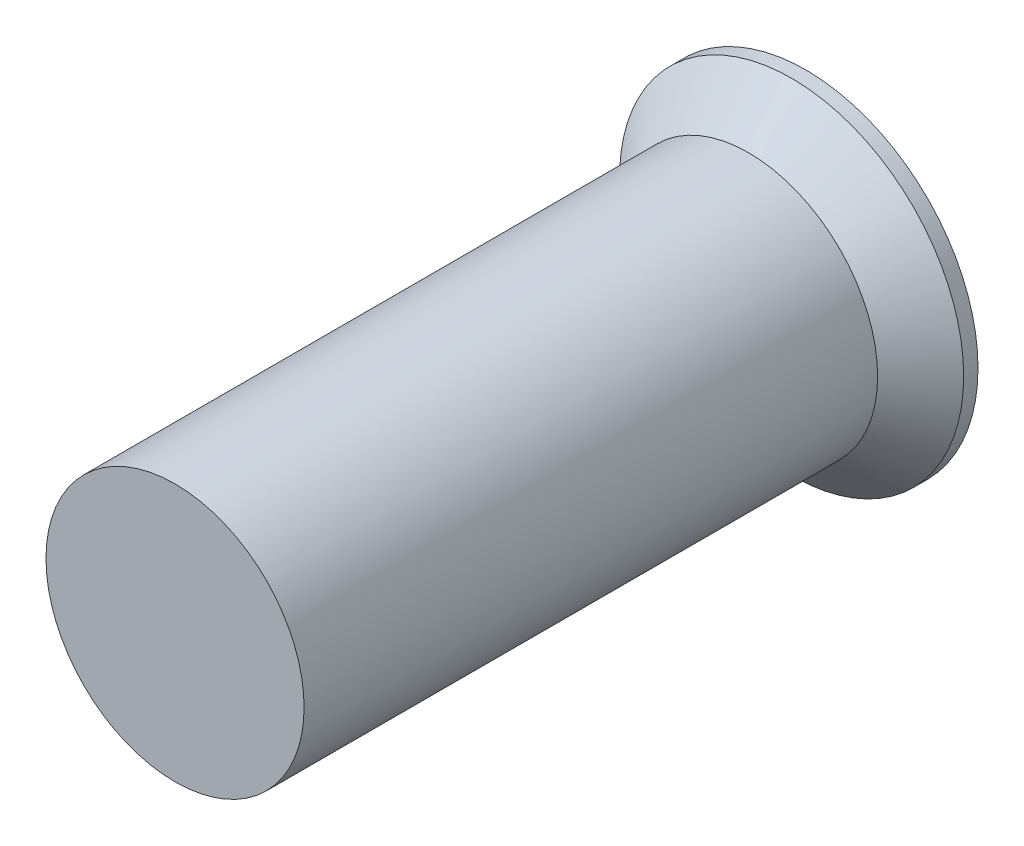
from build123d import *

# Parameters (mm, degrees)
ESQUISSE1_R        = 3
BOSS_EXTRU_1_DEPTH = 1
CHANFREIN1_SIZE    = 0.75
ESQUISSE2_R        = 2.25
BOSS_EXTRU_2_DEPTH = 10


with BuildPart() as part:
    # Esquisse1 → Boss.-Extru.1 (new body)
    with BuildSketch(Plane.XY):
        Circle(ESQUISSE1_R)
    extrude(amount=BOSS_EXTRU_1_DEPTH)

    # Chanfrein1
    chanfrein1_edges = [part.edges().sort_by_distance(p)[0] for p in [
        (-3, 0, 1),
    ]]
    chamfer(chanfrein1_edges, length=CHANFREIN1_SIZE)

    # Esquisse2 → Boss.-Extru.2 (add)
    with BuildSketch(Plane.XY.offset(1)):
        Circle(ESQUISSE2_R)
    extrude(amount=BOSS_EXTRU_2_DEPTH)


solid = part.part
